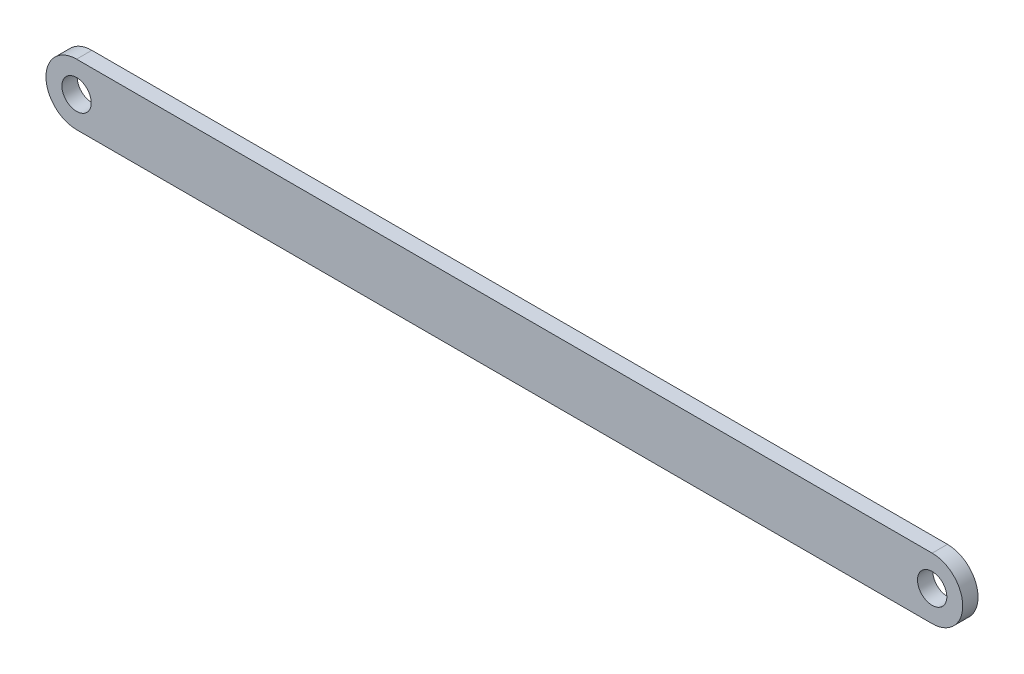
from build123d import *

# Parameters (mm, degrees)
SKETCH1_R           = 3.048
BOSS_EXTRUDE1_DEPTH = 3.175


with BuildPart() as part:
    # Sketch1 → Boss-Extrude1 (new body)
    with BuildSketch(Plane.XY):
        with BuildLine():
            Line((-88.9, -6.35), (88.9, -6.35))
            ThreePointArc((88.9, -6.35), (95.25, 0), (88.9, 6.35))
            Line((88.9, 6.35), (-88.9, 6.35))
            ThreePointArc((-88.9, 6.35), (-95.25, 0), (-88.9, -6.35))
        make_face()
        with Locations((-88.9, 0)):
            Circle(SKETCH1_R, mode=Mode.SUBTRACT)
        with Locations((88.9, 0)):
            Circle(SKETCH1_R, mode=Mode.SUBTRACT)
    extrude(amount=BOSS_EXTRUDE1_DEPTH)


solid = part.part
